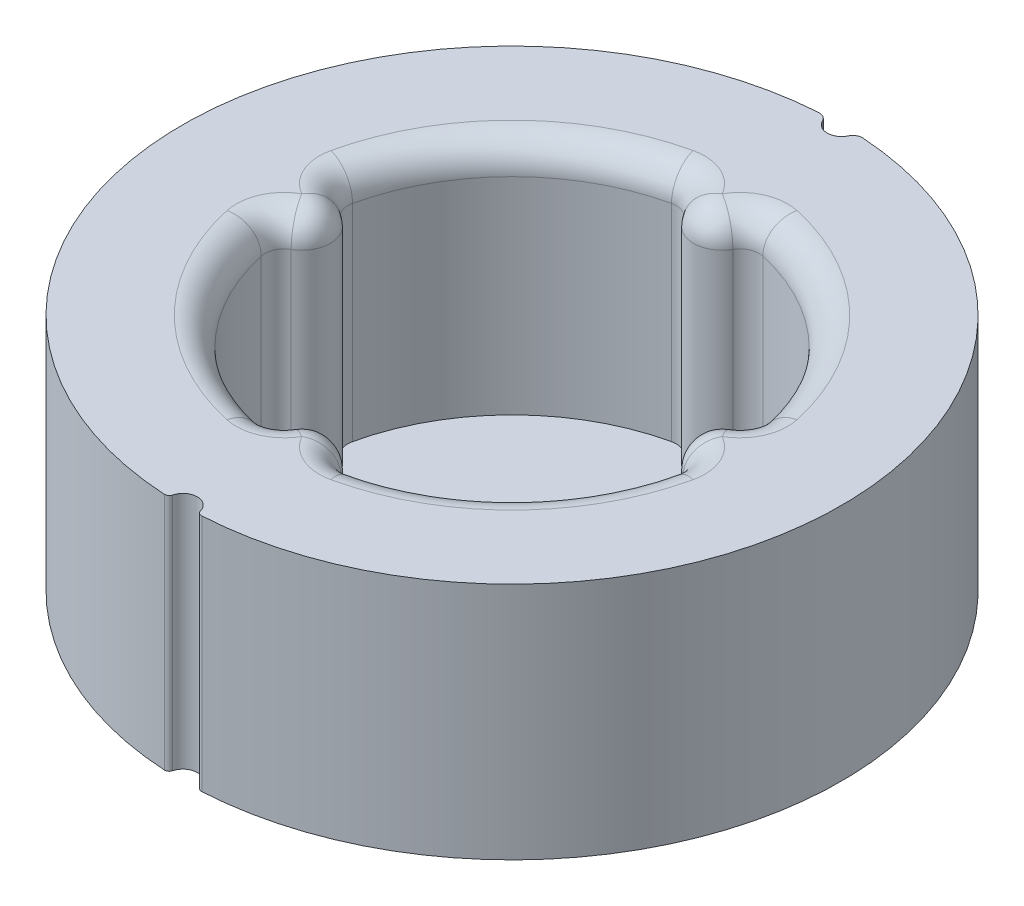
from build123d import *

# Parameters (mm, degrees)
BOSS_EXTRUDE1_DEPTH = 25
CUT_EXTRUDE2_DEPTH  = 55.786493398
BOSS_EXTRUDE2_DEPTH = 0.4
FILLET1_R           = 3


with BuildPart() as part:
    # Sketch1 → Boss-Extrude1 (new body)
    with BuildSketch(Plane(origin=(0, 0, 0), x_dir=(1, 0, 0), z_dir=(0, 1, 0))):
        with BuildLine():
            ThreePointArc((1.451818925, -34.068556857), (1.641248992, -34.346908706), (1.964225605, -34.442038138))
            ThreePointArc((1.964225605, -34.442038138), (26.591847487, -21.978073076), (34.198225299, 4.555174015))
            ThreePointArc((34.198225299, 4.555174015), (23.590291339, 25.176355888), (2.324135821, 34.423627607))
            ThreePointArc((2.324135821, 34.423627607), (1.751838249, 34.289058819), (1.354061739, 33.856153382))
            ThreePointArc((1.354061739, 33.856153382), (0, 33.001534515), (-1.354061739, 33.856153382))
            ThreePointArc((-1.354061739, 33.856153382), (-1.751838249, 34.289058819), (-2.324135821, 34.423627607))
            ThreePointArc((-2.324135821, 34.423627607), (-23.590291339, 25.176355888), (-34.198225299, 4.555174015))
            ThreePointArc((-34.198225299, 4.555174015), (-26.591847487, -21.978073076), (-1.964225605, -34.442038138))
            ThreePointArc((-1.964225605, -34.442038138), (-1.641248992, -34.346908706), (-1.451818925, -34.068556857))
            ThreePointArc((-1.451818925, -34.068556857), (0, -32.945679925), (1.451818925, -34.068556857))
        make_face()
        with BuildLine():
            Line((-2.417, 3.787737139), (0, 3.787737139))
            Line((0, 3.787737139), (2.417, 3.787737139))
            ThreePointArc((2.417, 3.787737139), (0, -4.489512172), (-2.417, 3.787737139))
        make_face(mode=Mode.SUBTRACT)
    extrude(amount=BOSS_EXTRUDE1_DEPTH)

    # Sketch2 → Cut-Extrude2 (cut, through all)
    with BuildSketch(Plane(origin=(0, 0, 0), x_dir=(1, 0, 0), z_dir=(0, 1, 0))):
        with BuildLine():
            ThreePointArc((-21.475, -4.777486264), (-15.556349186, -15.556349186), (-4.777486264, -21.475))
            ThreePointArc((-4.777486264, -21.475), (-3.533555097, -21.35153147), (-2.605901598, -20.513636364))
            ThreePointArc((-2.605901598, -20.513636364), (0, -19), (2.605901598, -20.513636364))
            ThreePointArc((2.605901598, -20.513636364), (3.533555097, -21.35153147), (4.777486264, -21.475))
            ThreePointArc((4.777486264, -21.475), (15.556349186, -15.556349186), (21.475, -4.777486264))
            ThreePointArc((21.475, -4.777486264), (21.35153147, -3.533555097), (20.513636364, -2.605901598))
            ThreePointArc((20.513636364, -2.605901598), (19, 0), (20.513636364, 2.605901598))
            ThreePointArc((20.513636364, 2.605901598), (21.35153147, 3.533555097), (21.475, 4.777486264))
            ThreePointArc((21.475, 4.777486264), (15.556349186, 15.556349186), (4.777486264, 21.475))
            ThreePointArc((4.777486264, 21.475), (3.533555097, 21.35153147), (2.605901598, 20.513636364))
            ThreePointArc((2.605901598, 20.513636364), (0, 19), (-2.605901598, 20.513636364))
            ThreePointArc((-2.605901598, 20.513636364), (-3.533555097, 21.35153147), (-4.777486264, 21.475))
            ThreePointArc((-4.777486264, 21.475), (-15.556349186, 15.556349186), (-21.475, 4.777486264))
            ThreePointArc((-21.475, 4.777486264), (-21.35153147, 3.533555097), (-20.513636364, 2.605901598))
            ThreePointArc((-20.513636364, 2.605901598), (-19, 0), (-20.513636364, -2.605901598))
            ThreePointArc((-20.513636364, -2.605901598), (-21.35153147, -3.533555097), (-21.475, -4.777486264))
        make_face()
    extrude(amount=CUT_EXTRUDE2_DEPTH, mode=Mode.SUBTRACT)

    # Sketch2_2 → Boss-Extrude2 (add)
    with BuildSketch(Plane(origin=(0, 0, 0), x_dir=(1, 0, 0), z_dir=(0, 1, 0))):
        with BuildLine():
            ThreePointArc((-21.475, -4.777486264), (-15.556349186, -15.556349186), (-4.777486264, -21.475))
            ThreePointArc((-4.777486264, -21.475), (-3.533555097, -21.35153147), (-2.605901598, -20.513636364))
            ThreePointArc((-2.605901598, -20.513636364), (0, -19), (2.605901598, -20.513636364))
            ThreePointArc((2.605901598, -20.513636364), (3.533555097, -21.35153147), (4.777486264, -21.475))
            ThreePointArc((4.777486264, -21.475), (15.556349186, -15.556349186), (21.475, -4.777486264))
            ThreePointArc((21.475, -4.777486264), (21.35153147, -3.533555097), (20.513636364, -2.605901598))
            ThreePointArc((20.513636364, -2.605901598), (19, 0), (20.513636364, 2.605901598))
            ThreePointArc((20.513636364, 2.605901598), (21.35153147, 3.533555097), (21.475, 4.777486264))
            ThreePointArc((21.475, 4.777486264), (15.556349186, 15.556349186), (4.777486264, 21.475))
            ThreePointArc((4.777486264, 21.475), (3.533555097, 21.35153147), (2.605901598, 20.513636364))
            ThreePointArc((2.605901598, 20.513636364), (0, 19), (-2.605901598, 20.513636364))
            ThreePointArc((-2.605901598, 20.513636364), (-3.533555097, 21.35153147), (-4.777486264, 21.475))
            ThreePointArc((-4.777486264, 21.475), (-15.556349186, 15.556349186), (-21.475, 4.777486264))
            ThreePointArc((-21.475, 4.777486264), (-21.35153147, 3.533555097), (-20.513636364, 2.605901598))
            ThreePointArc((-20.513636364, 2.605901598), (-19, 0), (-20.513636364, -2.605901598))
            ThreePointArc((-20.513636364, -2.605901598), (-21.35153147, -3.533555097), (-21.475, -4.777486264))
        make_face()
    extrude(amount=BOSS_EXTRUDE2_DEPTH)

    # Fillet1
    fillet1_edges = [part.edges().sort_by_distance(p)[0] for p in [
        (-21.35153147, 25, -3.533555097),
        (-19, 25, 0),
        (-21.35153147, 25, 3.533555097),
        (-15.556349186, 25, 15.556349186),
        (-3.533555097, 25, 21.35153147),
        (0, 25, 19),
        (3.533555097, 25, 21.35153147),
        (21.35153147, 25, 3.533555097),
        (15.556349186, 25, 15.556349186),
        (21.35153147, 25, -3.533555097),
        (19, 25, 0),
        (15.556349186, 25, -15.556349186),
        (3.533555097, 25, -21.35153147),
        (0, 25, -19),
        (-3.533555097, 25, -21.35153147),
        (-15.556349186, 25, -15.556349186),
    ]]
    fillet(fillet1_edges, radius=FILLET1_R)


solid = part.part
